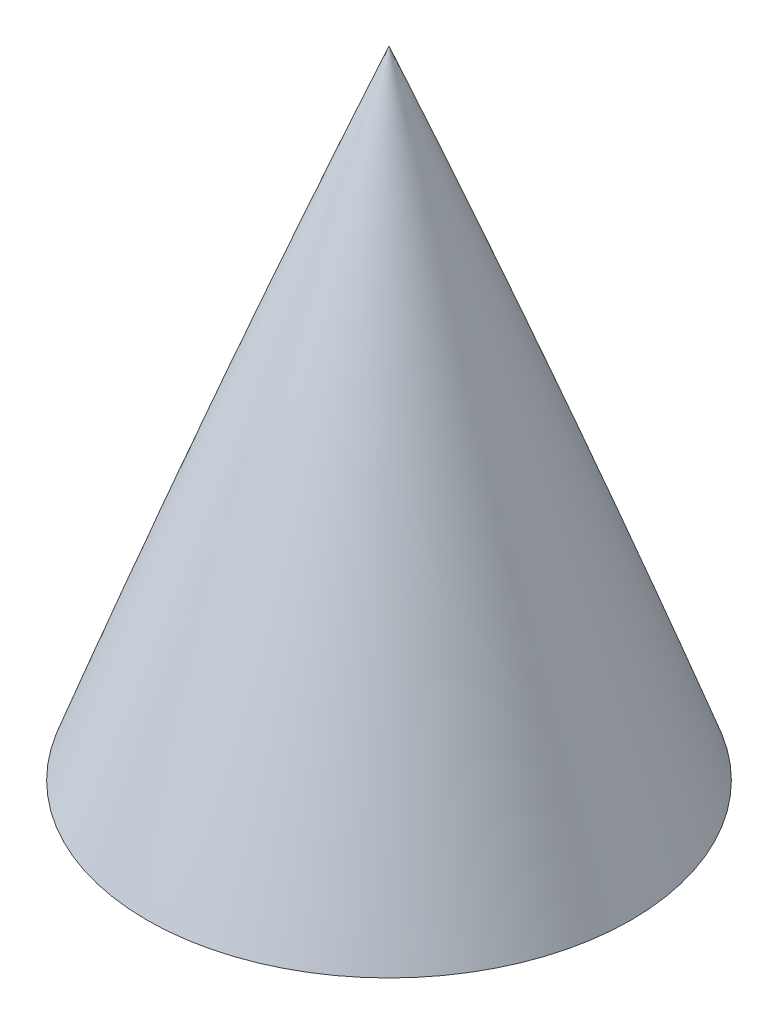
from build123d import *

# Parameters (mm, degrees)
SKETCH7_R          = 421.495799584
CUT_EXTRUDE2_DEPTH = 292.1
SKETCH8_R          = 2.413
CUT_EXTRUDE3_DEPTH = 12.7


with BuildPart() as part:
    # Sketch2 → Revolve1 (revolve)
    with BuildSketch(Plane.XY):
        with BuildLine():
            Line((-76.2, 0), (-69.85, 0))
            Line((-69.85, 0), (0, 0))
            Line((0, 0), (0, 325.12))
            Line((0, 325.12), (0, 330.2))
            ThreePointArc((0, 330.2), (-50.970594074, 168.070137094), (-76.2, 0))
        make_face()
    revolve(axis=Axis((0, 330.2, 0), (0, -1, 0)))

    # Sketch7 → Cut-Extrude2 (cut)
    with BuildSketch(Plane.XZ):
        with Locations((-188.314971498, 83.017725001)):
            Circle(SKETCH7_R)
    extrude(amount=-CUT_EXTRUDE2_DEPTH, mode=Mode.SUBTRACT)

    # Sketch8 → Cut-Extrude3 (cut)
    with BuildSketch(Plane(origin=(0, 292.1, 0), x_dir=(-1, 0, 0), z_dir=(0, -1, 0))):
        Circle(SKETCH8_R)
    extrude(amount=-CUT_EXTRUDE3_DEPTH, mode=Mode.SUBTRACT)


solid = part.part
